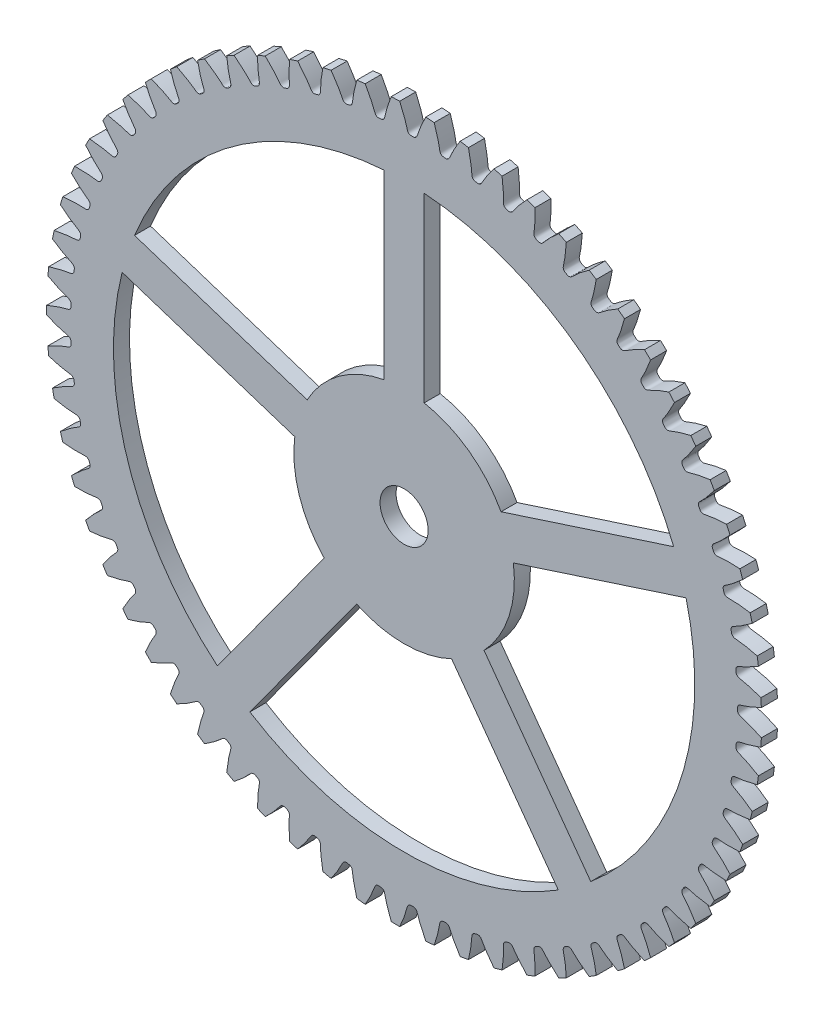
from build123d import *

# Parameters (mm, degrees)
SKETCHREVOLVEENGRANAJE_ARRIBA_8_9_W       = 0.2
SKETCHREVOLVEENGRANAJE_ARRIBA_8_9_H       = 4.458076923
TOOTHEXTRUDECUTENGRANAJE_ARRIBA_8_9_DEPTH = 0.1
PATTERNENGRANAJE_ARRIBA_8_9_COUNT         = 65
CORTAR_EXTRUIR1_REACH                     = 8.308
CROQUIS1_R                                = 0.3


with BuildPart() as part:
    # SketchRevolveEngranaje Arriba_8.9 → Engranaje Arriba_8.9 (revolve)
    with BuildSketch(Plane(origin=(0, 0, 0), x_dir=(0, 0, -1), z_dir=(1, 0, 0))):
        with Locations((0, 2.229038462)):
            Rectangle(SKETCHREVOLVEENGRANAJE_ARRIBA_8_9_W, SKETCHREVOLVEENGRANAJE_ARRIBA_8_9_H)
    revolve(axis=Axis((0, 0, 0), (0, 0, -1)))

    # SketchToothEngranaje Arriba_8.9 → ToothExtrudeCutEngranaje Arriba_8.9 (cut, symmetric)
    with BuildSketch(Plane.XY):
        with BuildLine():
            ThreePointArc((4.455100159, 0.16288778), (4.458076923, 0), (4.455100159, -0.16288778))
            add(Edge.make_bspline(
                [(4.455100159, -0.16288778), (4.439126341, -0.154972228), (4.417922343, -0.144846559), (4.391477622, -0.132881108), (4.376293177, -0.126193908), (4.361420804, -0.119822091), (4.346865278, -0.113758685), (4.332631261, -0.107996646), (4.318723307, -0.102528874), (4.305145863, -0.097348194), (4.29190325, -0.092447422), (4.278999725, -0.087819137), (4.266439259, -0.083456495), (4.254226334, -0.079350353), (4.242363092, -0.075499487), (4.230859467, -0.071874315), (4.218409544, -0.068161575), (4.208914752, -0.065211342), (4.202121046, -0.063464292), (4.199358528, -0.062647276), (4.196623435, -0.061763527), (4.19390344, -0.060789694), (4.191180117, -0.059710044), (4.188432775, -0.058498759), (4.185637265, -0.057121548), (4.182766835, -0.055530808), (4.179794003, -0.053660987), (4.176695355, -0.051422338), (4.173461656, -0.048694604), (4.170116657, -0.04532403), (4.166748436, -0.041132299), (4.163545645, -0.035951903), (4.160833946, -0.029704299), (4.159043879, -0.022714008), (4.158354836, -0.01267379), (4.158857406, 0), (4.158354836, 0.01267379), (4.159043879, 0.022714008), (4.160833946, 0.029704299), (4.163545645, 0.035951903), (4.166748436, 0.041132299), (4.170116657, 0.04532403), (4.173461656, 0.048694604), (4.176695355, 0.051422338), (4.179794003, 0.053660987), (4.182766835, 0.055530808), (4.185637265, 0.057121548), (4.188432775, 0.058498759), (4.191180117, 0.059710044), (4.19390344, 0.060789694), (4.196623435, 0.061763527), (4.199358528, 0.062647276), (4.202121046, 0.063464292), (4.208914752, 0.065211342), (4.218409544, 0.068161575), (4.230859467, 0.071874315), (4.242363092, 0.075499487), (4.254226334, 0.079350353), (4.266439259, 0.083456495), (4.278999725, 0.087819137), (4.29190325, 0.092447422), (4.305145863, 0.097348194), (4.318723307, 0.102528874), (4.332631261, 0.107996646), (4.346865278, 0.113758685), (4.361420804, 0.119822091), (4.376293177, 0.126193908), (4.391477622, 0.132881108), (4.417922343, 0.144846559), (4.439126341, 0.154972228), (4.455100159, 0.16288778)],
                knots=[0, 0, 0, 0, 0.074782027, 0.098557693, 0.121757413, 0.144381189, 0.166429019, 0.187900905, 0.208796846, 0.229116841, 0.248860892, 0.268028998, 0.286621159, 0.304637375, 0.322077645, 0.338941971, 0.355230352, 0.37657994, 0.380633396, 0.384653158, 0.388662356, 0.392689539, 0.396770213, 0.400948831, 0.40528136, 0.409838469, 0.414709264, 0.420005046, 0.42586159, 0.432436465, 0.439894527, 0.448371361, 0.457907047, 0.468363367, 0.478462435, 0.5, 0.521537565, 0.531636633, 0.542092953, 0.551628639, 0.560105473, 0.567563535, 0.57413841, 0.579994954, 0.585290736, 0.590161531, 0.59471864, 0.599051169, 0.603229787, 0.607310461, 0.611337644, 0.615346842, 0.619366604, 0.62342006, 0.644769648, 0.661058029, 0.677922355, 0.695362625, 0.713378841, 0.731971002, 0.751139108, 0.770883159, 0.791203154, 0.812099095, 0.833570981, 0.855618811, 0.878242587, 0.901442307, 0.925217973, 1, 1, 1, 1], degree=3))
        make_face()
    toothextrudecutengranaje_arriba_8_9 = extrude(amount=TOOTHEXTRUDECUTENGRANAJE_ARRIBA_8_9_DEPTH, both=True, mode=Mode.SUBTRACT)

    # PatternEngranaje Arriba_8.9: ToothExtrudeCutEngranaje Arriba_8.9 ×65 about axis
    patternengranaje_arriba_8_9_axis = Axis((0, 0, 55), (0, 0, -1))
    for i in range(1, PATTERNENGRANAJE_ARRIBA_8_9_COUNT):
        add(toothextrudecutengranaje_arriba_8_9.rotate(patternengranaje_arriba_8_9_axis, i * 360 / PATTERNENGRANAJE_ARRIBA_8_9_COUNT), mode=Mode.SUBTRACT)

    # Croquis1 → Cortar-Extruir1 (cut, up to next)
    with BuildSketch(Plane.XY.offset(0.1), mode=Mode.PRIVATE) as cortar_extruir1_sk1:
        with BuildLine():
            Line((1.923394137, -3.072650321), (0.592479451, -1.240803409))
            ThreePointArc((0.592479451, -1.240803409), (0, -1.375), (-0.592479451, -1.240803409))
            Line((-0.592479451, -1.240803409), (-1.923394137, -3.072650321))
            ThreePointArc((-1.923394137, -3.072650321), (0, -3.625), (1.923394137, -3.072650321))
        make_face()
    cortar_extruir1_tool1 = extrude(cortar_extruir1_sk1.sketch, amount=-CORTAR_EXTRUIR1_REACH, mode=Mode.PRIVATE) & part.part
    # Croquis1 → Cortar-Extruir1 (cut, up to next)
    with BuildSketch(Plane.XY.offset(0.1), mode=Mode.PRIVATE) as cortar_extruir1_sk2:
        with BuildLine():
            ThreePointArc((0.25, 1.352081728), (0.808204722, 1.112398367), (1.20865189, 0.655580361))
            Line((1.20865189, 0.655580361), (3.362117088, 1.355283619))
            ThreePointArc((3.362117088, 1.355283619), (2.13072154, 2.932686605), (0.25, 3.616369035))
            Line((0.25, 3.616369035), (0.25, 1.352081728))
        make_face()
    cortar_extruir1_tool2 = extrude(cortar_extruir1_sk2.sketch, amount=-CORTAR_EXTRUIR1_REACH, mode=Mode.PRIVATE) & part.part
    # Croquis1 → Cortar-Extruir1 (cut, up to next)
    with BuildSketch(Plane.XY.offset(0.1), mode=Mode.PRIVATE) as cortar_extruir1_sk3:
        with BuildLine():
            Line((3.516625585, 0.879755361), (1.363160387, 0.180052103))
            ThreePointArc((1.363160387, 0.180052103), (1.30770271, -0.424898367), (0.996987948, -0.946910783))
            Line((0.996987948, -0.946910783), (2.327902634, -2.778757694))
            ThreePointArc((2.327902634, -2.778757694), (3.447579872, -1.120186605), (3.516625585, 0.879755361))
        make_face()
    cortar_extruir1_tool3 = extrude(cortar_extruir1_sk3.sketch, amount=-CORTAR_EXTRUIR1_REACH, mode=Mode.PRIVATE) & part.part
    # Croquis1 → Cortar-Extruir1 (cut, up to next)
    with BuildSketch(Plane.XY.offset(0.1), mode=Mode.PRIVATE) as cortar_extruir1_sk4:
        with BuildLine():
            Line((-3.362117088, 1.355283619), (-1.20865189, 0.655580361))
            ThreePointArc((-1.20865189, 0.655580361), (-0.808204722, 1.112398367), (-0.25, 1.352081728))
            Line((-0.25, 1.352081728), (-0.25, 3.616369035))
            ThreePointArc((-0.25, 3.616369035), (-2.13072154, 2.932686605), (-3.362117088, 1.355283619))
        make_face()
    cortar_extruir1_tool4 = extrude(cortar_extruir1_sk4.sketch, amount=-CORTAR_EXTRUIR1_REACH, mode=Mode.PRIVATE) & part.part
    # Croquis1 → Cortar-Extruir1 (cut, up to next)
    with BuildSketch(Plane.XY.offset(0.1), mode=Mode.PRIVATE) as cortar_extruir1_sk5:
        with BuildLine():
            ThreePointArc((-0.996987948, -0.946910783), (-1.30770271, -0.424898367), (-1.363160387, 0.180052103))
            Line((-1.363160387, 0.180052103), (-3.516625585, 0.879755361))
            ThreePointArc((-3.516625585, 0.879755361), (-3.447579872, -1.120186605), (-2.327902634, -2.778757694))
            Line((-2.327902634, -2.778757694), (-0.996987948, -0.946910783))
        make_face()
    cortar_extruir1_tool5 = extrude(cortar_extruir1_sk5.sketch, amount=-CORTAR_EXTRUIR1_REACH, mode=Mode.PRIVATE) & part.part
    # Croquis1 → Cortar-Extruir1 (cut, up to next)
    with BuildSketch(Plane.XY.offset(0.1), mode=Mode.PRIVATE) as cortar_extruir1_sk6:
        Circle(CROQUIS1_R)
    cortar_extruir1_tool6 = extrude(cortar_extruir1_sk6.sketch, amount=-CORTAR_EXTRUIR1_REACH, mode=Mode.PRIVATE) & part.part
    add(cortar_extruir1_tool1.solids().sort_by_distance((0, -2.573389, 0.1))[0], mode=Mode.SUBTRACT)
    add(cortar_extruir1_tool2.solids().sort_by_distance((1.5126, 2.081915, 0.1))[0], mode=Mode.SUBTRACT)
    add(cortar_extruir1_tool3.solids().sort_by_distance((2.447438, -0.795221, 0.1))[0], mode=Mode.SUBTRACT)
    add(cortar_extruir1_tool4.solids().sort_by_distance((-1.5126, 2.081915, 0.1))[0], mode=Mode.SUBTRACT)
    add(cortar_extruir1_tool5.solids().sort_by_distance((-2.447438, -0.795221, 0.1))[0], mode=Mode.SUBTRACT)
    add(cortar_extruir1_tool6.solids().sort_by_distance((0, 0, 0.1))[0], mode=Mode.SUBTRACT)


solid = part.part
